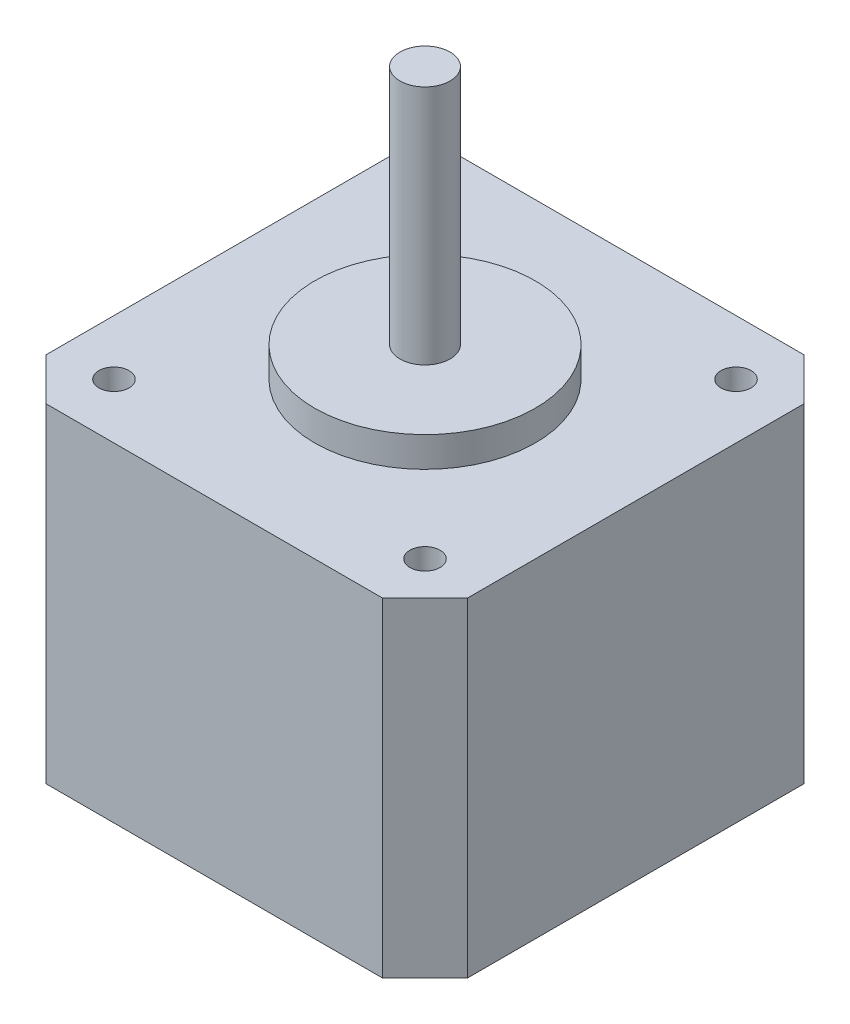
from build123d import *

# Parameters (mm, degrees)
BOSS_EXTRUDE1_DEPTH = 32.8
SKETCH2_R           = 1.5
CUT_EXTRUDE1_DEPTH  = 10
SKETCH3_R           = 11
BOSS_EXTRUDE2_DEPTH = 3
SKETCH4_R           = 2.5
BOSS_EXTRUDE3_DEPTH = 24


with BuildPart() as part:
    # Sketch1 → Boss-Extrude1 (new body)
    with BuildSketch(Plane(origin=(0, 0, 0), x_dir=(1, 0, 0), z_dir=(0, 1, 0))):
        Polygon((-19, 21), (-21, 19), (-21, -16.76), (-16.76, -21), (16.76, -21), (21, -16.76), (21, 16.76), (16.76, 21), align=None)
    extrude(amount=BOSS_EXTRUDE1_DEPTH)

    # Sketch2 → Cut-Extrude1 (cut)
    with BuildSketch(Plane(origin=(0, 32.8, 0), x_dir=(1, 0, 0), z_dir=(0, 1, 0))):
        with Locations((15.5, 15.5)):
            Circle(SKETCH2_R)
        with Locations((15.5, -15.5)):
            Circle(SKETCH2_R)
        with Locations((-15.5, -15.5)):
            Circle(SKETCH2_R)
        with Locations((-15.5, 15.5)):
            Circle(SKETCH2_R)
    extrude(amount=-CUT_EXTRUDE1_DEPTH, mode=Mode.SUBTRACT)

    # Sketch3 → Boss-Extrude2 (add)
    with BuildSketch(Plane(origin=(0, 32.8, 0), x_dir=(1, 0, 0), z_dir=(0, 1, 0))):
        Circle(SKETCH3_R)
    extrude(amount=BOSS_EXTRUDE2_DEPTH)

    # Sketch4 → Boss-Extrude3 (add)
    with BuildSketch(Plane(origin=(0, 35.8, 0), x_dir=(1, 0, 0), z_dir=(0, 1, 0))):
        Circle(SKETCH4_R)
    extrude(amount=BOSS_EXTRUDE3_DEPTH)


solid = part.part
